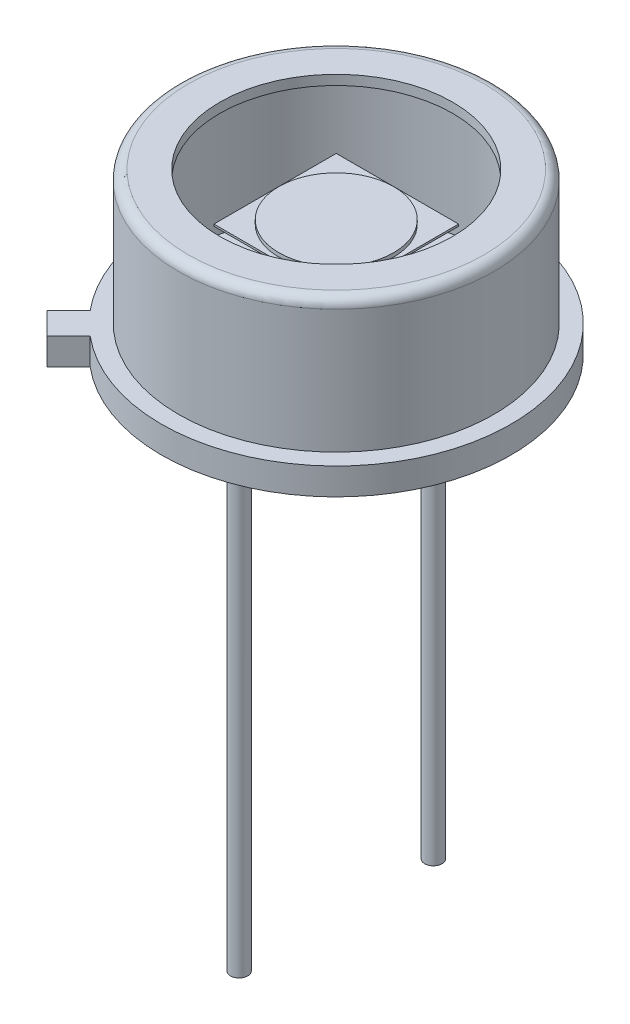
from build123d import *

# Parameters (mm, degrees)
SKETCH2_R           = 4.57
BOSS_EXTRUDE1_DEPTH = 0.446
BOSS_EXTRUDE8_DEPTH = 0.7
BOSS_EXTRUDE2_START = -2.95
SKETCH3_W           = 3.2
SKETCH3_H           = 3.2
BOSS_EXTRUDE2_DEPTH = 0.05
SKETCH8_R           = 1.5
BOSS_EXTRUDE6_DEPTH = 0.1
SKETCH5_R           = 0.225
BOSS_EXTRUDE4_DEPTH = 12.7
SKETCH9_R           = 0.5
BOSS_EXTRUDE7_DEPTH = 0.01


with BuildPart() as part:
    # Sketch1 → Revolve-Thin2 (revolve)
    with BuildSketch(Plane.XY, mode=Mode.PRIVATE) as revolve_thin2_sk:
        with BuildLine():
            Line((4.57, 0), (4.57, 0.7))
            Line((4.57, 0.7), (4.125, 0.7))
            Line((4.125, 0.7), (4.125, 3.936))
            ThreePointArc((4.125, 3.936), (4.050605122, 4.115605122), (3.871, 4.19))
            Line((3.871, 4.19), (3.045, 4.19))
            Line((3.045, 4.19), (3.045, 3.936))
            Line((3.045, 3.936), (3.871, 3.936))
            Line((3.871, 3.936), (3.871, 0.446))
            Line((3.871, 0.446), (4.316, 0.446))
            Line((4.316, 0.446), (4.316, 0))
            Line((4.316, 0), (4.57, 0))
        make_face()
    revolve(revolve_thin2_sk.sketch.rotate(Axis((0, 0, 0), (0, 1, 0)), 90), axis=Axis((0, 0, 0), (0, 1, 0)))  # turned: the seam where the file's is

    # Sketch2 → Boss-Extrude1 (add)
    with BuildSketch(Plane.XZ):
        with Locations(Location((0, 0, 0), (0, 0, 270))):  # turned: the seam where the file's is
            Circle(SKETCH2_R)
    extrude(amount=-BOSS_EXTRUDE1_DEPTH)

    # Sketch11 → Boss-Extrude8 (add)
    with BuildSketch(Plane.XZ):
        with BuildLine():
            Line((-3.498070528, 4.070827021), (-3.784448774, 3.784448774))
            Line((-3.784448774, 3.784448774), (-4.070827021, 3.498070528))
            Line((-4.070827021, 3.498070528), (-3.505141596, 2.932385103))
            ThreePointArc((-3.505141596, 2.932385103), (-3.23147799, 3.23147799), (-2.932385103, 3.505141596))
            Line((-2.932385103, 3.505141596), (-3.498070528, 4.070827021))
        make_face()
    extrude(amount=-BOSS_EXTRUDE8_DEPTH)

    # Sketch5 → Boss-Extrude4 (add)
    with BuildSketch(Plane.XZ):
        with Locations(Location((0, -2.54, 0), (0, 0, 90))):  # turned: the seam where the file's is
            Circle(SKETCH5_R)
        with Locations(Location((0, 2.54, 0), (0, 0, 90))):  # turned: the seam where the file's is
            Circle(SKETCH5_R)
    extrude(amount=BOSS_EXTRUDE4_DEPTH)

    # Sketch9 → Boss-Extrude7 (add)
    with BuildSketch(Plane.XZ):
        with Locations(Location((0, -3.8, 0), (0, 0, 90))):  # turned: the seam where the file's is
            Circle(SKETCH9_R)
    extrude(amount=BOSS_EXTRUDE7_DEPTH)


with BuildPart() as body_2:
    # Sketch3 → Boss-Extrude2 (new body)
    with BuildSketch(Plane.XZ.offset(BOSS_EXTRUDE2_START)):
        Rectangle(SKETCH3_W, SKETCH3_H)
    extrude(amount=BOSS_EXTRUDE2_DEPTH)

    # Sketch8 → Boss-Extrude6 (add)
    with BuildSketch(Plane(origin=(0, 2.95, 0), x_dir=(-1, 0, 0), z_dir=(0, 1, 0))):
        with Locations(Location((0, 0, 0), (0, 0, 270))):  # turned: the seam where the file's is
            Circle(SKETCH8_R)
    extrude(amount=BOSS_EXTRUDE6_DEPTH)


solid = Compound([part.part, body_2.part])
